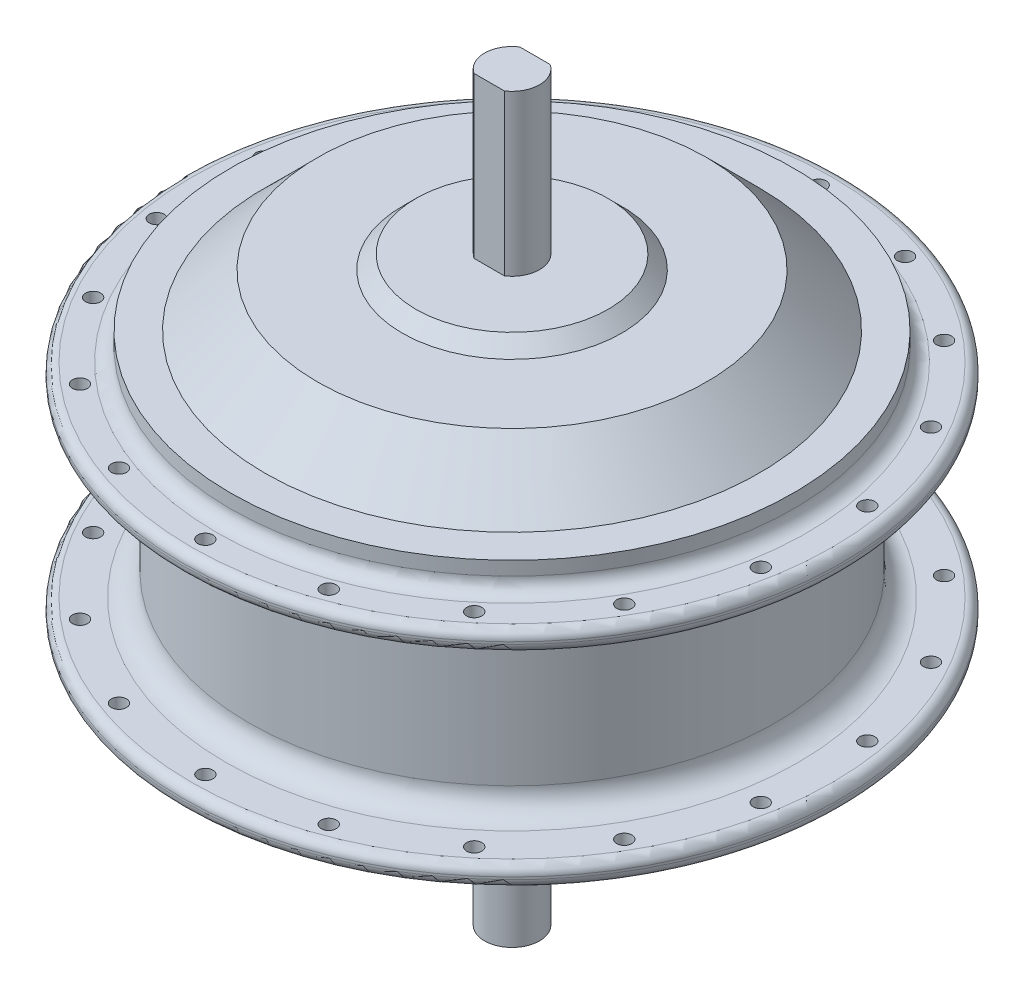
from build123d import *

# Parameters (mm, degrees)
FILLET_1_R               = 2
FILLET_2_R               = 5
FILLET_3_R               = 3
CUT_EXTRUDE_1_DEPTH      = 35
SKETCH_3_R               = 1.65
CUT_EXTRUDE_2_DEPTH      = 58.5
CUT_EXTRUDE_2_DEPTH_BACK = 105.5


with BuildPart() as part:
    # Эскиз1 → Повернуть1 (revolve)
    with BuildSketch(Plane(origin=(0, 0, 0), x_dir=(0, 0, -1), z_dir=(1, 0, 0))):
        Polygon((0, 80), (-6, 80), (-6, 45), (-21, 45), (-24, 42), (-42.5, 42), (-54, 30.5), (-61.5, 30.5), (-61.5, 24.5), (-72, 24.5), (-72, 20), (-57.5, 20), (-57.5, -20), (-72, -20), (-72, -24.5), (-62, -24.5), (-62, -30.5), (-54, -30.5), (-42.5, -42), (-26.65, -42), (-26.65, -51), (-6, -51), (-6, -82), (0, -82), align=None)
    revolve(axis=Axis((0, 80, 0), (0, -1, 0)))

    # Скругление1
    fillet_1_edges = [part.edges().sort_by_distance(p)[0] for p in [
        (0, -24.5, -72),
        (0, -20, -72),
        (0, 20, -72),
        (0, 24.5, -72),
    ]]
    fillet(fillet_1_edges, radius=FILLET_1_R)

    # Скругление2
    fillet_2_edges = [part.edges().sort_by_distance(p)[0] for p in [
        (0, -20, -57.5),
        (0, 20, -57.5),
    ]]
    fillet(fillet_2_edges, radius=FILLET_2_R)

    # Скругление3
    fillet_3_edges = [part.edges().sort_by_distance(p)[0] for p in [
        (0, -24.5, -62),
        (0, 24.5, -61.5),
    ]]
    fillet(fillet_3_edges, radius=FILLET_3_R)

    # Эскиз2 → Вырез-Вытянуть1 (cut)
    with BuildSketch(Plane(origin=(0, 80, 0), x_dir=(1, 0, 0), z_dir=(0, 1, 0))):
        with BuildLine():
            Line((-3.31662479, 5), (3.31662479, 5))
            ThreePointArc((3.31662479, 5), (0, 6), (-3.31662479, 5))
        make_face()
        with BuildLine():
            Line((-3.31662479, -5), (3.31662479, -5))
            ThreePointArc((3.31662479, -5), (0, -6), (-3.31662479, -5))
        make_face()
    extrude(amount=-CUT_EXTRUDE_1_DEPTH, mode=Mode.SUBTRACT)

    # Эскиз3 → Вырез-Вытянуть2 (cut, two sides)
    with BuildSketch(Plane.XZ.offset(24.5)) as cut_extrude_2_sk:
        with Locations((0, 67)):
            Circle(SKETCH_3_R)
        with Locations((22.915349603, 62.959405593)):
            Circle(SKETCH_3_R)
        with Locations((43.066769849, 51.324977689)):
            Circle(SKETCH_3_R)
        with Locations((58.023702054, 33.5)):
            Circle(SKETCH_3_R)
        with Locations((65.982119452, 11.634427904)):
            Circle(SKETCH_3_R)
        with Locations((65.982119452, -11.634427904)):
            Circle(SKETCH_3_R)
        with Locations((58.023702054, -33.5)):
            Circle(SKETCH_3_R)
        with Locations((43.066769849, -51.324977689)):
            Circle(SKETCH_3_R)
        with Locations((22.915349603, -62.959405593)):
            Circle(SKETCH_3_R)
        with Locations((0, -67)):
            Circle(SKETCH_3_R)
        with Locations((-22.915349603, -62.959405593)):
            Circle(SKETCH_3_R)
        with Locations((-43.066769849, -51.324977689)):
            Circle(SKETCH_3_R)
        with Locations((-58.023702054, -33.5)):
            Circle(SKETCH_3_R)
        with Locations((-65.982119452, -11.634427904)):
            Circle(SKETCH_3_R)
        with Locations((-65.982119452, 11.634427904)):
            Circle(SKETCH_3_R)
        with Locations((-58.023702054, 33.5)):
            Circle(SKETCH_3_R)
        with Locations((-43.066769849, 51.324977689)):
            Circle(SKETCH_3_R)
        with Locations((-22.915349603, 62.959405593)):
            Circle(SKETCH_3_R)
    extrude(amount=CUT_EXTRUDE_2_DEPTH, mode=Mode.SUBTRACT)
    extrude(cut_extrude_2_sk.sketch, amount=-CUT_EXTRUDE_2_DEPTH_BACK, mode=Mode.SUBTRACT)


solid = part.part
